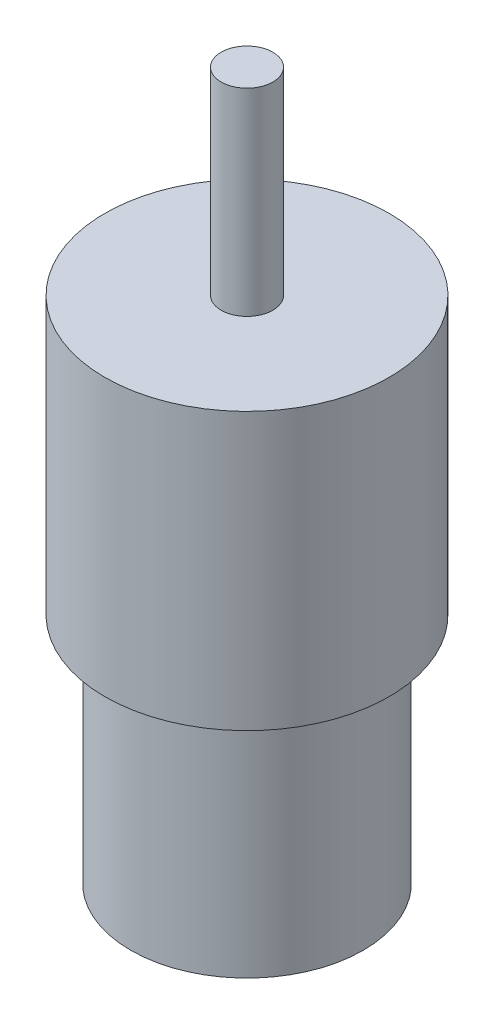
from build123d import *

# Parameters (mm, degrees)
CROQUIS1_R              = 11
SALIENTE_EXTRUIR1_DEPTH = 21.4
CROQUIS2_R              = 2
SALIENTE_EXTRUIR2_DEPTH = 15.3
CROQUIS3_R              = 9
SALIENTE_EXTRUIR3_DEPTH = 18


with BuildPart() as part:
    # Croquis1 → Saliente-Extruir1 (new body)
    with BuildSketch(Plane(origin=(0, 0, 0), x_dir=(1, 0, 0), z_dir=(0, 1, 0))):
        Circle(CROQUIS1_R)
    extrude(amount=SALIENTE_EXTRUIR1_DEPTH)

    # Croquis2 → Saliente-Extruir2 (add)
    with BuildSketch(Plane(origin=(0, 21.4, 0), x_dir=(1, 0, 0), z_dir=(0, 1, 0))):
        Circle(CROQUIS2_R)
    extrude(amount=SALIENTE_EXTRUIR2_DEPTH)

    # Croquis3 → Saliente-Extruir3 (add)
    with BuildSketch(Plane.XZ):
        Circle(CROQUIS3_R)
    extrude(amount=SALIENTE_EXTRUIR3_DEPTH)


solid = part.part
